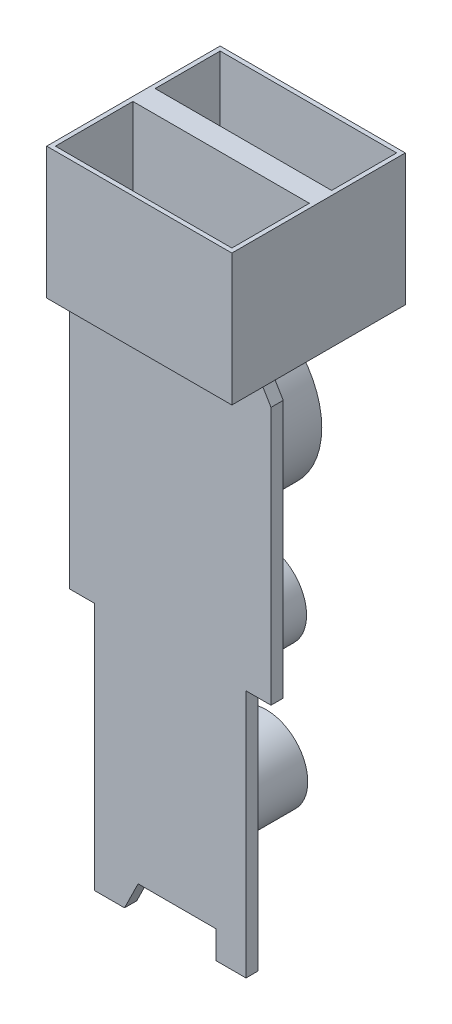
from build123d import *

# Parameters (mm, degrees)
SKETCH1_W           = 14.07
SKETCH1_H           = 13.18
BOSS_EXTRUDE1_DEPTH = 5
SKETCH2_W           = 13.41
SKETCH2_H           = 4.94
SKETCH2_H_2         = 5.888730893
CUT_EXTRUDE1_DEPTH  = 9
BOSS_EXTRUDE2_START = 3.3
BOSS_EXTRUDE2_DEPTH = 0.93
BOSS_EXTRUDE3_START = 3.3
SKETCH5_R           = 6.26
BOSS_EXTRUDE3_DEPTH = 5.6
BOSS_EXTRUDE4_START = 3.3
SKETCH7_R           = 3.2
BOSS_EXTRUDE4_DEPTH = 8.1
BOSS_EXTRUDE5_START = 3.3
SKETCH8_R           = 3.165
BOSS_EXTRUDE5_DEPTH = 8.3


with BuildPart() as part:
    # Sketch1 → Boss-Extrude1 (new body, symmetric)
    with BuildSketch(Plane(origin=(0, 0, 0), x_dir=(1, 0, 0), z_dir=(0, 1, 0))):
        Rectangle(SKETCH1_W, SKETCH1_H)
    extrude(amount=BOSS_EXTRUDE1_DEPTH, both=True)

    # Sketch2 → Cut-Extrude1 (cut)
    with BuildSketch(Plane(origin=(0, 5, 0), x_dir=(1, 0, 0), z_dir=(0, 1, 0))):
        with Locations((0, 3.79)):
            Rectangle(SKETCH2_W, SKETCH2_H)
        with Locations((0, -3.315634554)):
            Rectangle(SKETCH2_W, SKETCH2_H_2)
    extrude(amount=-CUT_EXTRUDE1_DEPTH, mode=Mode.SUBTRACT)

    # Sketch3 → Boss-Extrude2 (add)
    with BuildSketch(Plane.XY.offset(BOSS_EXTRUDE2_START)):
        Polygon((7.035, -5), (7.65, -6.03042467), (7.65, -25.63042467), (5.75, -25.63042467), (5.75, -44.53042467), (3.48, -44.53042467), (3.48, -42.43042467), (-2.448967454, -42.43042467), (-3.48, -44.53042467), (-5.75, -44.53042467), (-5.75, -25.63042467), (-7.65, -25.63042467), (-7.65, -6.03042467), (-7.035, -5), align=None)
    extrude(amount=BOSS_EXTRUDE2_DEPTH)

    # Sketch5 → Boss-Extrude3 (add)
    with BuildSketch(Plane.XY.offset(BOSS_EXTRUDE3_START)):
        with Locations((-1.283039212, -11.96715887)):
            Circle(SKETCH5_R)
    extrude(amount=-BOSS_EXTRUDE3_DEPTH)

    # Sketch7 → Boss-Extrude4 (add)
    with BuildSketch(Plane.XY.offset(BOSS_EXTRUDE4_START)):
        with Locations((-1.877046038, -27.386019249)):
            Circle(SKETCH7_R)
    extrude(amount=-BOSS_EXTRUDE4_DEPTH)

    # Sketch8 → Boss-Extrude5 (add)
    with BuildSketch(Plane.XY.offset(BOSS_EXTRUDE5_START)):
        with Locations((-1.952127879, -38.498131793)):
            Circle(SKETCH8_R)
    extrude(amount=-BOSS_EXTRUDE5_DEPTH)


solid = part.part
